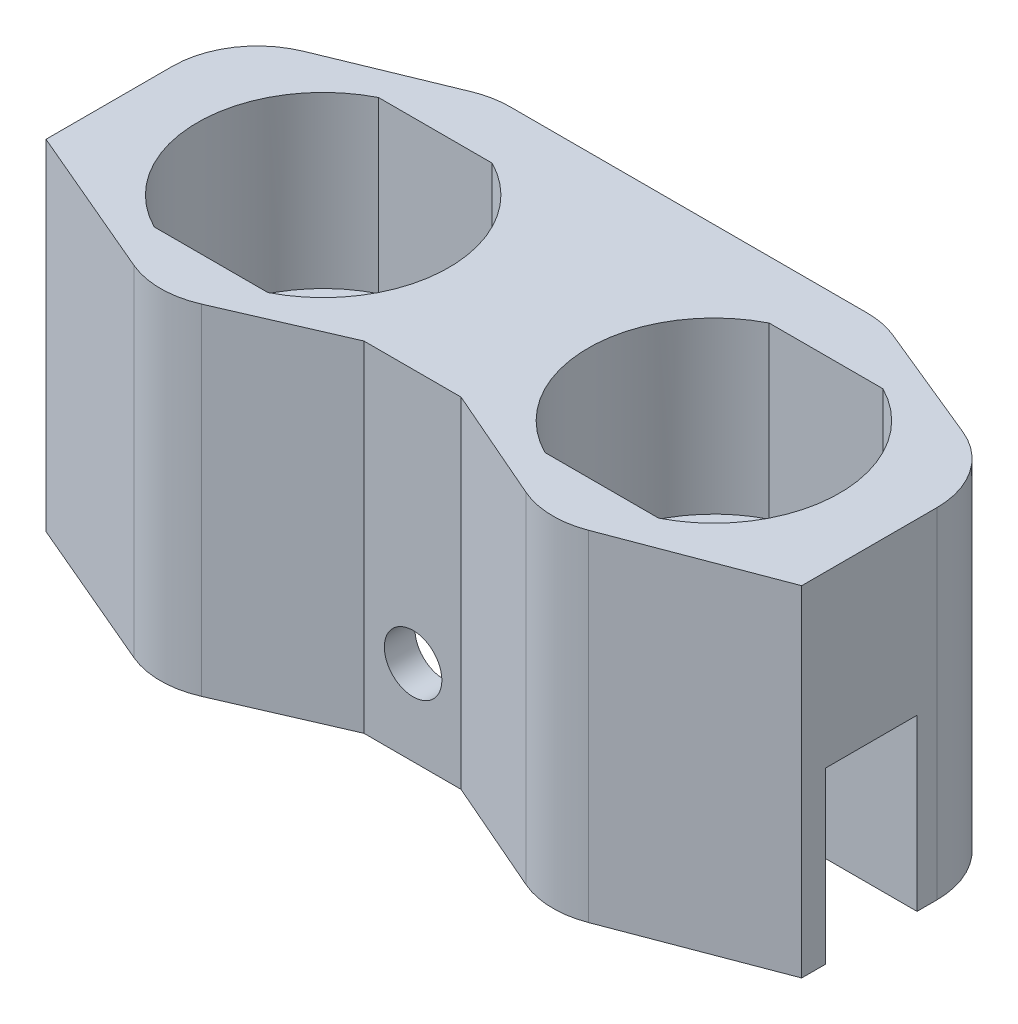
from build123d import *

# Parameters (mm, degrees)
SKETCH1_W               = 57.15
SKETCH1_H               = 25.4
BOSS_EXTRUDE1_DEPTH     = 12.7
BOSS_EXTRUDE3_DEPTH     = 12.7
CUT_EXTRUDE1_DEPTH      = 26.4
CUT_EXTRUDE2_DEPTH      = 26.4
FILLET1_R               = 6.35
SKETCH7_W               = 12.7
SKETCH7_H               = 2.286
BOSS_EXTRUDE4_DEPTH     = 25.4
SKETCH6_R               = 2.15
CUT_EXTRUDE3_DEPTH      = 14.413396589
CUT_EXTRUDE3_DEPTH_BACK = 12.4837718


with BuildPart() as part:
    # Sketch1 → Boss-Extrude1 (new body)
    with BuildSketch(Plane(origin=(0, 0, 0), x_dir=(1, 0, 0), z_dir=(0, 1, 0))):
        with Locations((14.605, 0)):
            Rectangle(SKETCH1_W, SKETCH1_H)
        with BuildLine():
            Line((-4.250232935, 8.382), (4.250232935, 8.382))
            ThreePointArc((4.250232935, 8.382), (9.398, 0), (4.250232935, -8.382))
            Line((4.250232935, -8.382), (-4.250232935, -8.382))
            ThreePointArc((-4.250232935, -8.382), (-9.398, 0), (-4.250232935, 8.382))
        make_face(mode=Mode.SUBTRACT)
        with BuildLine():
            Line((24.959767065, 8.382), (33.460232935, 8.382))
            ThreePointArc((33.460232935, 8.382), (38.608, 0), (33.460232935, -8.382))
            Line((33.460232935, -8.382), (24.959767065, -8.382))
            ThreePointArc((24.959767065, -8.382), (19.812, 0), (24.959767065, 8.382))
        make_face(mode=Mode.SUBTRACT)
    extrude(amount=BOSS_EXTRUDE1_DEPTH)

    # Sketch3 → Boss-Extrude3 (add)
    with BuildSketch(Plane.XZ):
        Polygon((-13.97, 12.7), (43.18, 12.7), (43.18, 5.6417718), (32.093467094, 5.6417718), (26.326532906, 5.6417718), (2.727750443, 5.6417718), (-2.727750443, 5.6417718), (-13.97, 5.6417718), align=None)
        with BuildLine():
            Line((43.18, -1.2162282), (43.18, -12.7))
            Line((43.18, -12.7), (-13.97, -12.7))
            Line((-13.97, -12.7), (-13.97, -1.2162282))
            Line((-13.97, -1.2162282), (-5.584085777, -1.2162282))
            ThreePointArc((-5.584085777, -1.2162282), (0, -5.715), (5.584085777, -1.2162282))
            Line((5.584085777, -1.2162282), (23.717811699, -1.2162282))
            ThreePointArc((23.717811699, -1.2162282), (29.21, -5.625241627), (34.702188301, -1.2162282))
            Line((34.702188301, -1.2162282), (43.18, -1.2162282))
        make_face()
    extrude(amount=BOSS_EXTRUDE3_DEPTH)

    # Sketch4 → Cut-Extrude1 (cut, through all)
    with BuildSketch(Plane.XZ.offset(12.7)):
        Polygon((-13.97, -6.9581141), (-13.97, -12.7), (0, -12.7), align=None)
        Polygon((29.21, -12.7), (43.18, -12.7), (43.18, -6.9581141), align=None)
        Polygon((43.18, 12.7), (43.18, 7.40632885), (29.21, 12.7), align=None)
        Polygon((0, 12.7), (-13.97, 6.751), (-13.97, 12.7), align=None)
    extrude(amount=-CUT_EXTRUDE1_DEPTH, mode=Mode.SUBTRACT)

    # Sketch5 → Cut-Extrude2 (cut, through all)
    with BuildSketch(Plane.XZ.offset(12.7)):
        Polygon((0, 12.7), (14.605, 6.35), (29.21, 12.7), align=None)
    extrude(amount=-CUT_EXTRUDE2_DEPTH, mode=Mode.SUBTRACT)

    # Fillet1
    fillet1_edges = [part.edges().sort_by_distance(p)[0] for p in [
        (0, 0, 12.7),
        (29.21, 0, 12.7),
        (29.21, 0, -12.7),
        (43.18, 0, -6.9581141),
        (-13.97, 0, -6.9581141),
        (0, 0, -12.7),
    ]]
    fillet(fillet1_edges, radius=FILLET1_R)

    # Sketch7 → Boss-Extrude4 (add)
    with BuildSketch(Plane.XZ.offset(12.7)):
        with Locations((14.605, 6.7847718)):
            Rectangle(SKETCH7_W, SKETCH7_H)
    extrude(amount=-BOSS_EXTRUDE4_DEPTH)

    # Sketch6 → Cut-Extrude3 (cut, two sides)
    with BuildSketch(Plane.XY.offset(-1.2162282)) as cut_extrude3_sk:
        with Locations((14.650948738, -6.35)):
            Circle(SKETCH6_R)
    extrude(amount=CUT_EXTRUDE3_DEPTH, mode=Mode.SUBTRACT)
    extrude(cut_extrude3_sk.sketch, amount=-CUT_EXTRUDE3_DEPTH_BACK, mode=Mode.SUBTRACT)


solid = part.part
